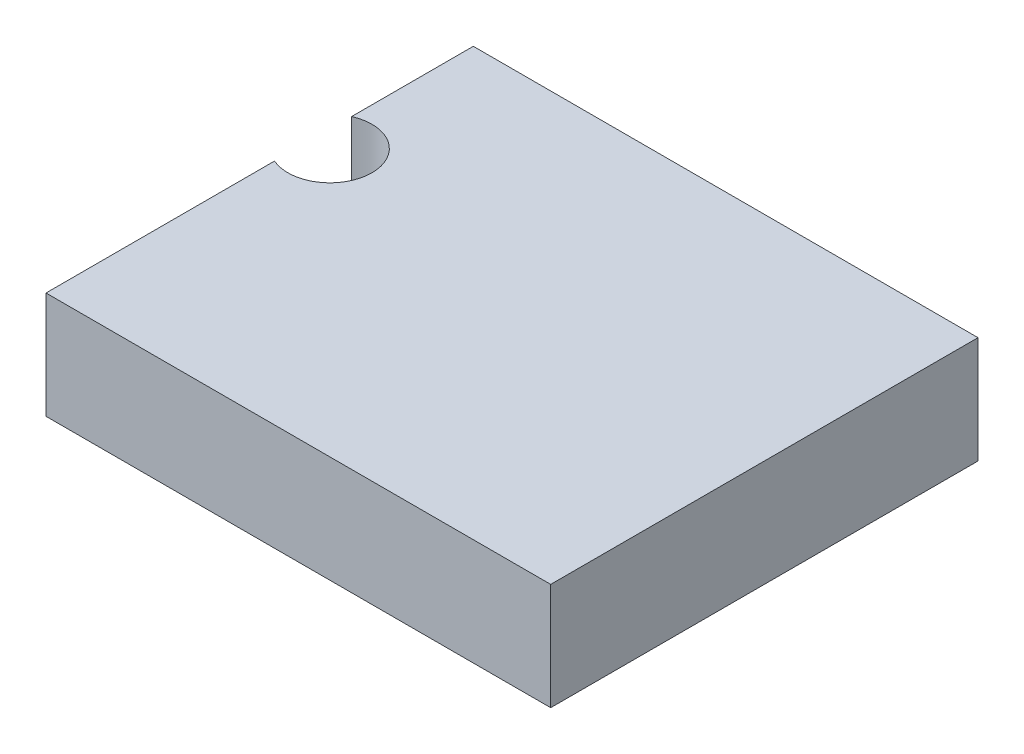
from build123d import *

# Parameters (mm, degrees)
SKETCH1_W           = 30
SKETCH1_H           = 25.4
BOSS_EXTRUDE1_DEPTH = 6.35
SKETCH2_R           = 2.5
CUT_EXTRUDE1_DEPTH  = 7.35


with BuildPart() as part:
    # Sketch1 → Boss-Extrude1 (new body)
    with BuildSketch(Plane(origin=(0, 0, 0), x_dir=(1, 0, 0), z_dir=(0, 1, 0))):
        Rectangle(SKETCH1_W, SKETCH1_H)
    extrude(amount=BOSS_EXTRUDE1_DEPTH)

    # Sketch2 → Cut-Extrude1 (cut, through all)
    with BuildSketch(Plane(origin=(0, 6.35, 0), x_dir=(1, 0, 0), z_dir=(0, 1, 0))):
        with Locations((-14, 3.175)):
            Circle(SKETCH2_R)
    extrude(amount=-CUT_EXTRUDE1_DEPTH, mode=Mode.SUBTRACT)


solid = part.part
